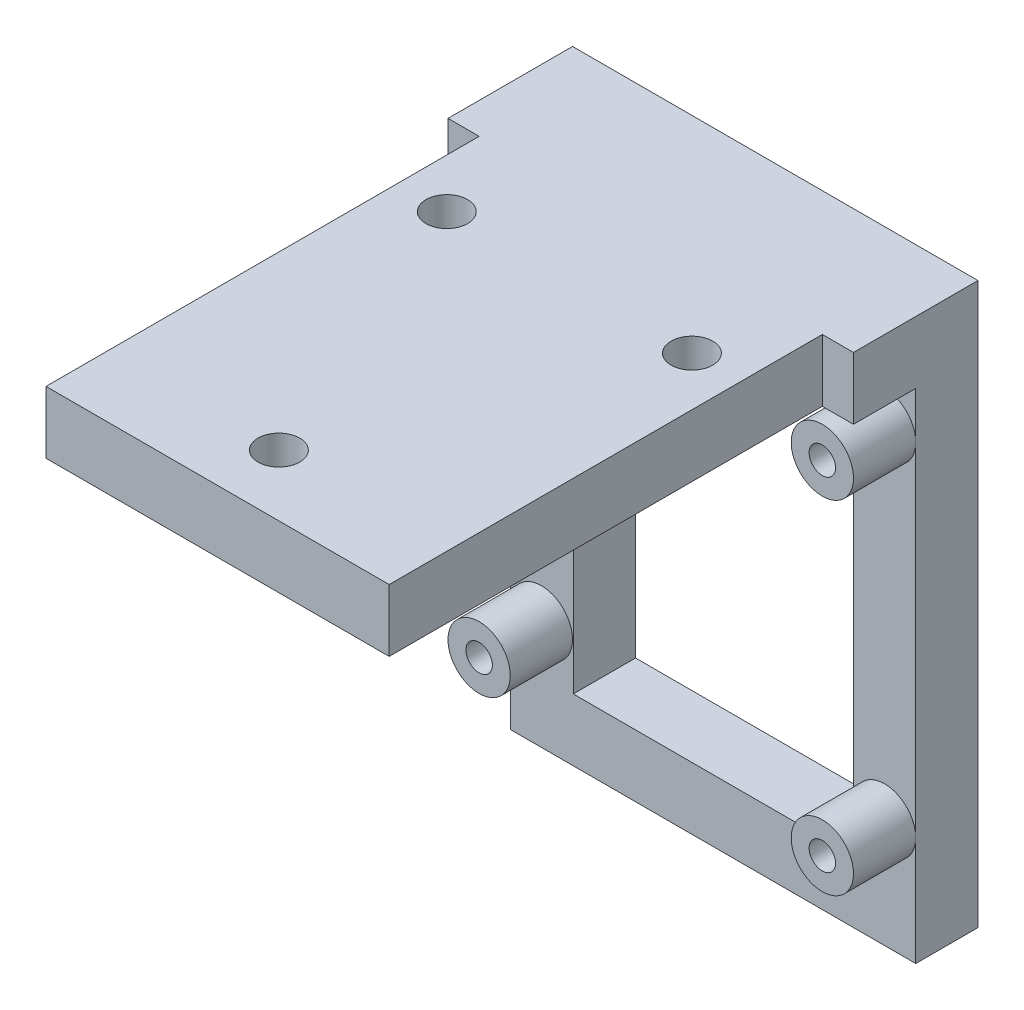
from build123d import *

# Parameters (mm, degrees)
SKETCH1_W               = 33.08
SKETCH1_H               = 45.5
BOSS_EXTRUDE1_DEPTH     = 5.08
SKETCH2_R               = 1.7
CUT_EXTRUDE1_DEPTH      = 6.08
SKETCH3_W               = 33.08
SKETCH3_H               = 5.08
BOSS_EXTRUDE2_DEPTH     = 40.64
SKETCH4_R               = 1.0795
SKETCH4_W               = 22.86
SKETCH4_H               = 35.56
CUT_EXTRUDE2_DEPTH      = 41.42
CUT_EXTRUDE2_DEPTH_BACK = 6.08
SKETCH5_R               = 2.54
SKETCH5_R_2             = 1.0795
BOSS_EXTRUDE3_DEPTH     = 5.08
SKETCH6_W               = 2.54
SKETCH6_H               = 35.34
CUT_EXTRUDE3_DEPTH      = 6.08


with BuildPart() as part:
    # Sketch1 → Boss-Extrude1 (new body)
    with BuildSketch(Plane(origin=(0, 0, 0), x_dir=(1, 0, 0), z_dir=(0, 1, 0))):
        with Locations((16.54, 22.75)):
            Rectangle(SKETCH1_W, SKETCH1_H)
    extrude(amount=BOSS_EXTRUDE1_DEPTH)

    # Sketch2 → Cut-Extrude1 (cut, through all)
    with BuildSketch(Plane.XZ):
        with Locations((6.54, -28.7)):
            Circle(SKETCH2_R)
        with Locations((26.54, -28.7)):
            Circle(SKETCH2_R)
        with Locations((16.54, -5)):
            Circle(SKETCH2_R)
    extrude(amount=-CUT_EXTRUDE1_DEPTH, mode=Mode.SUBTRACT)

    # Sketch3 → Boss-Extrude2 (add)
    with BuildSketch(Plane.XZ):
        with Locations((16.54, -42.96)):
            Rectangle(SKETCH3_W, SKETCH3_H)
    extrude(amount=BOSS_EXTRUDE2_DEPTH)

    # Sketch4 → Cut-Extrude2 (cut, two sides)
    with BuildSketch(Plane.XY.offset(-40.42)) as cut_extrude2_sk:
        with Locations((30.54, -31.75)):
            Circle(SKETCH4_R)
        with Locations((2.54, -31.75)):
            Circle(SKETCH4_R)
        with Locations((30.54, -3.81)):
            Circle(SKETCH4_R)
        with Locations((2.54, -3.81)):
            Circle(SKETCH4_R)
        with Locations((16.57, -17.78)):
            Rectangle(SKETCH4_W, SKETCH4_H)
    extrude(amount=CUT_EXTRUDE2_DEPTH, mode=Mode.SUBTRACT)
    extrude(cut_extrude2_sk.sketch, amount=-CUT_EXTRUDE2_DEPTH_BACK, mode=Mode.SUBTRACT)

    # Sketch5 → Boss-Extrude3 (add)
    with BuildSketch(Plane.XY.offset(-40.42)):
        with Locations((30.54, -31.75)):
            Circle(SKETCH5_R)
        with Locations((30.54, -31.75)):
            Circle(SKETCH5_R_2, mode=Mode.SUBTRACT)
        with Locations((30.54, -3.81)):
            Circle(SKETCH5_R)
        with Locations((30.54, -3.81)):
            Circle(SKETCH5_R_2, mode=Mode.SUBTRACT)
        with Locations((2.54, -3.81)):
            Circle(SKETCH5_R)
        with Locations((2.54, -3.81)):
            Circle(SKETCH5_R_2, mode=Mode.SUBTRACT)
        with Locations((2.54, -31.75)):
            Circle(SKETCH5_R)
        with Locations((2.54, -31.75)):
            Circle(SKETCH5_R_2, mode=Mode.SUBTRACT)
    extrude(amount=BOSS_EXTRUDE3_DEPTH)

    # Sketch6 → Cut-Extrude3 (cut, through all)
    with BuildSketch(Plane.XZ):
        with Locations((1.27, -17.67)):
            Rectangle(SKETCH6_W, SKETCH6_H)
        with Locations((31.81, -17.67)):
            Rectangle(SKETCH6_W, SKETCH6_H)
    extrude(amount=-CUT_EXTRUDE3_DEPTH, mode=Mode.SUBTRACT)


solid = part.part
